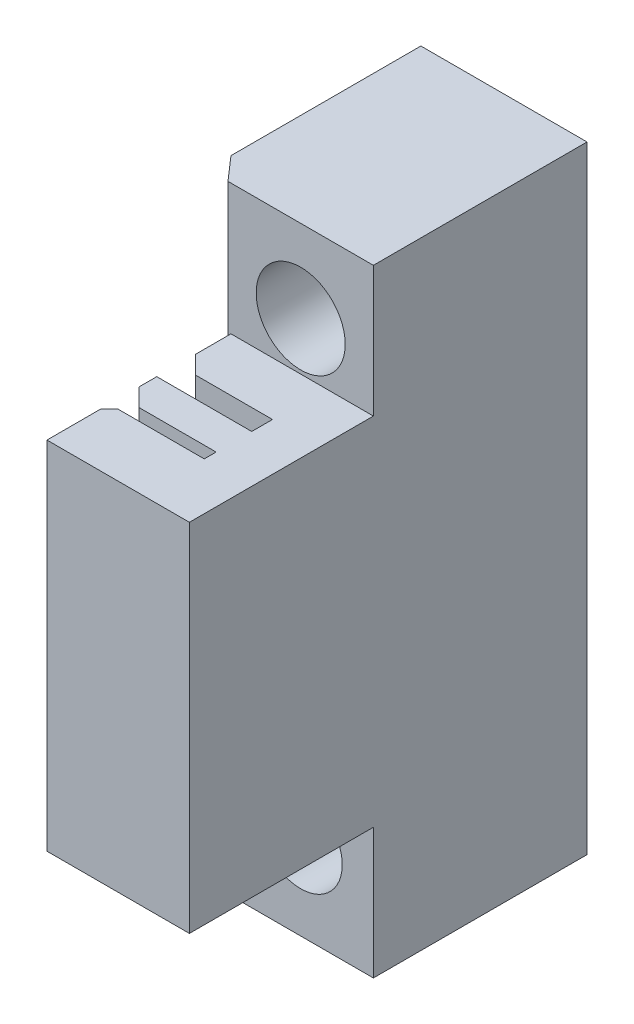
from build123d import *

# Parameters (mm, degrees)
BOSS_EXTRUDE1_DEPTH        = 26
BOSS_EXTRUDE2_DEPTH        = 15
SKETCH3_W                  = 1
SKETCH3_H                  = 1
BOSS_EXTRUDE3_DEPTH        = 8
CHAMFER1_SIZE              = 0.75
LPATTERN1_COUNT            = 15
LPATTERN1_PITCH            = 2
CHAMFER1_OF_LPATTERN1_SIZE = 0.75
SKETCH5_W                  = 1
SKETCH5_H                  = 1
BOSS_EXTRUDE4_DEPTH        = 8
CHAMFER2_SIZE              = 0.75
LPATTERN2_COUNT            = 15
LPATTERN2_PITCH            = 2
CHAMFER2_OF_LPATTERN2_SIZE = 0.75
SKETCH6_R                  = 2.1
CUT_EXTRUDE1_DEPTH         = 30
SKETCH7_R                  = 3.75
SKETCH7_R_2                = 3.5
CUT_EXTRUDE2_DEPTH         = 7


with BuildPart() as part:
    # Sketch1 → Boss-Extrude1 (new body, symmetric)
    with BuildSketch(Plane(origin=(0, 0, 0), x_dir=(1, 0, 0), z_dir=(0, 1, 0))):
        Polygon((0, 0), (14, 0), (14, -18), (1.75, -18), (0, -16), align=None)
    extrude(amount=BOSS_EXTRUDE1_DEPTH, both=True)

    # Sketch2 → Boss-Extrude2 (add, symmetric)
    with BuildSketch(Plane(origin=(0, 0, 0), x_dir=(1, 0, 0), z_dir=(0, 1, 0))):
        Polygon((14, -18), (14, -33.5), (2, -33.5), (2, -29.25), (10, -29.25), (10, -27.25), (3.5, -27.25), (2, -25.75), (2, -24.25), (10, -24.25), (10, -22.5), (3.5, -22.5), (2, -21), (2, -18), align=None)
    extrude(amount=BOSS_EXTRUDE2_DEPTH, both=True)

    # Sketch3 → Boss-Extrude3 (add)
    with BuildSketch(Plane.ZY.offset(-10)):
        with Locations((28.75, 14.5)):
            Rectangle(SKETCH3_W, SKETCH3_H)
    boss_extrude3 = extrude(amount=BOSS_EXTRUDE3_DEPTH)

    # Chamfer1
    chamfer1_edges = [part.edges().sort_by_distance(p)[0] for p in [
        (2, 14.5, 28.25),
    ]]
    chamfer(chamfer1_edges, length=CHAMFER1_SIZE)

    # LPattern1: Boss-Extrude3 ×15
    with Locations(*[(0, -i * LPATTERN1_PITCH, 0) for i in range(1, LPATTERN1_COUNT)]):
        add(boss_extrude3)

    # Chamfer1 of LPattern1
    chamfer1_of_lpattern1_edges = [part.edges().sort_by_distance(p)[0] for p in [
        (2, 12.5, 28.25),
        (2, 10.5, 28.25),
        (2, 8.5, 28.25),
        (2, 6.5, 28.25),
        (2, 4.5, 28.25),
        (2, 2.5, 28.25),
        (2, 0.5, 28.25),
        (2, -1.5, 28.25),
        (2, -3.5, 28.25),
        (2, -5.5, 28.25),
        (2, -7.5, 28.25),
        (2, -9.5, 28.25),
        (2, -11.5, 28.25),
        (2, -13.5, 28.25),
    ]]
    chamfer(chamfer1_of_lpattern1_edges, length=CHAMFER1_OF_LPATTERN1_SIZE)

    # Sketch5 → Boss-Extrude4 (add)
    with BuildSketch(Plane.ZY.offset(-10)):
        with Locations((23.75, -14.5)):
            Rectangle(SKETCH5_W, SKETCH5_H)
    boss_extrude4 = extrude(amount=BOSS_EXTRUDE4_DEPTH)

    # Chamfer2
    chamfer2_edges = [part.edges().sort_by_distance(p)[0] for p in [
        (2, -14.5, 23.25),
    ]]
    chamfer(chamfer2_edges, length=CHAMFER2_SIZE)

    # LPattern2: Boss-Extrude4 ×15
    with Locations(*[(0, i * LPATTERN2_PITCH, 0) for i in range(1, LPATTERN2_COUNT)]):
        add(boss_extrude4)

    # Chamfer2 of LPattern2
    chamfer2_of_lpattern2_edges = [part.edges().sort_by_distance(p)[0] for p in [
        (2, -12.5, 23.25),
        (2, -10.5, 23.25),
        (2, -8.5, 23.25),
        (2, -6.5, 23.25),
        (2, -4.5, 23.25),
        (2, -2.5, 23.25),
        (2, -0.5, 23.25),
        (2, 1.5, 23.25),
        (2, 3.5, 23.25),
        (2, 5.5, 23.25),
        (2, 7.5, 23.25),
        (2, 9.5, 23.25),
        (2, 11.5, 23.25),
        (2, 13.5, 23.25),
    ]]
    chamfer(chamfer2_of_lpattern2_edges, length=CHAMFER2_OF_LPATTERN2_SIZE)

    # Sketch6 → Cut-Extrude1 (cut)
    with BuildSketch(Plane.XY.offset(18)):
        with Locations((7.875, 19.05)):
            Circle(SKETCH6_R)
        with Locations((7.875, -19.05)):
            Circle(SKETCH6_R)
    extrude(amount=-CUT_EXTRUDE1_DEPTH, mode=Mode.SUBTRACT)

    # Sketch7 → Cut-Extrude2 (cut)
    with BuildSketch(Plane.XY.offset(18)):
        with Locations((7.875, 19.05)):
            Circle(SKETCH7_R)
        with Locations((7.875, -19.05)):
            Circle(SKETCH7_R_2)
    extrude(amount=-CUT_EXTRUDE2_DEPTH, mode=Mode.SUBTRACT)


solid = part.part
